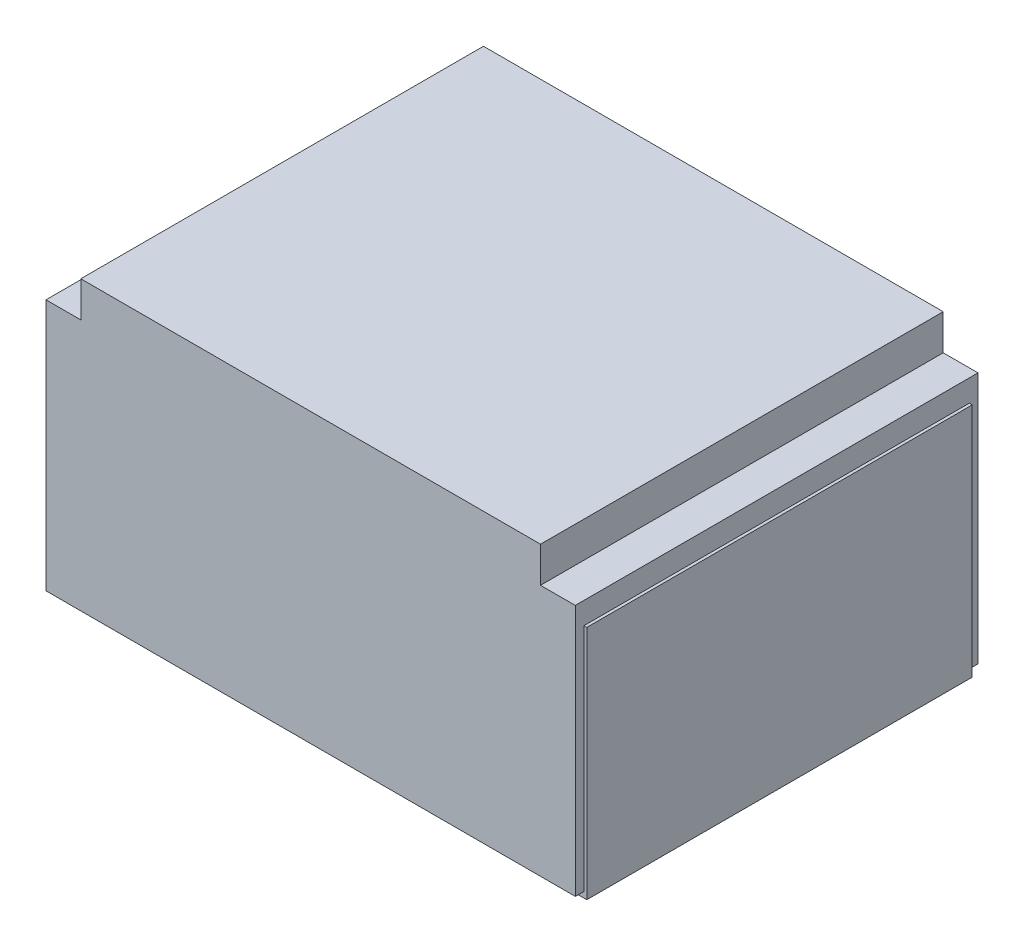
from build123d import *

# Parameters (mm, degrees)
SZKIC1_W                    = 4.6
SZKIC1_H                    = 2.5
DODANIE_WYCI_GNI_CIE1_DEPTH = 3.5
SZKIC2_W                    = 0.302200239
SZKIC2_H                    = 0.309416308
WYTNIJ_WYCI_GNI_CIE1_DEPTH  = 4.5
SZKIC3_W                    = 4.65
SZKIC3_H                    = 3.35
DODANIE_WYCI_GNI_CIE2_DEPTH = 0.05
SZKIC4_R                    = 0.162382369
SZKIC4_R_2                  = 1.05
WYTNIJ_WYCI_GNI_CIE2_DEPTH  = 0.05
SZKIC5_R                    = 1
DODANIE_WYCI_GNI_CIE3_DEPTH = 0.4
ZAOKR_GLENIE1_R             = 0.05
SZKIC6_W                    = 0.025
SZKIC6_H                    = 3.35
DODANIE_WYCI_GNI_CIE4_DEPTH = 2


with BuildPart() as part:
    # Szkic1 → Dodanie-wyciągnięcie1 (new body)
    with BuildSketch(Plane.XY):
        Rectangle(SZKIC1_W, SZKIC1_H)
    extrude(amount=DODANIE_WYCI_GNI_CIE1_DEPTH)

    # Szkic2 → Wytnij-wyciągnięcie1 (cut, through all)
    with BuildSketch(Plane.XY.offset(3.5)):
        with Locations((-2.148899881, 1.095291846)):
            Rectangle(SZKIC2_W, SZKIC2_H)
        with Locations((2.148899881, 1.095291846)):
            Rectangle(SZKIC2_W, SZKIC2_H)
    extrude(amount=-WYTNIJ_WYCI_GNI_CIE1_DEPTH, mode=Mode.SUBTRACT)


with BuildPart() as body_2:
    # Szkic3 → Dodanie-wyciągnięcie2 (new body)
    with BuildSketch(Plane.XZ.offset(1.25)):
        with Locations((0, 1.75)):
            Rectangle(SZKIC3_W, SZKIC3_H)
    extrude(amount=DODANIE_WYCI_GNI_CIE2_DEPTH)

    # Szkic4 → Wytnij-wyciągnięcie2 (cut)
    with BuildSketch(Plane.XZ.offset(1.3)):
        with Locations((-1.92312306, 3.089394939)):
            Circle(SZKIC4_R)
        with Locations((1.92312306, 3.089394939)):
            Circle(SZKIC4_R)
        with Locations((0, 1.59590093)):
            Circle(SZKIC4_R_2)
        Polygon((-1.74824974, 0.075), (-1.74824974, 0.441313237), (-1.648322128, 0.441313237), (-1.473448808, 0.191494209), (1.473448808, 0.191494209), (1.648322128, 0.441313237), (1.74824974, 0.441313237), (1.74824974, 0.075), align=None)
    extrude(amount=-WYTNIJ_WYCI_GNI_CIE2_DEPTH, mode=Mode.SUBTRACT)

    # Szkic6 → Dodanie-wyciągnięcie4 (add)
    with BuildSketch(Plane(origin=(0, -1.25, 0), x_dir=(1, 0, 0), z_dir=(0, 1, 0))):
        with Locations((-2.3125, -1.75)):
            Rectangle(SZKIC6_W, SZKIC6_H)
        with Locations((2.3125, -1.75)):
            Rectangle(SZKIC6_W, SZKIC6_H)
    extrude(amount=DODANIE_WYCI_GNI_CIE4_DEPTH)


with BuildPart() as body_3:
    # Szkic5 → Dodanie-wyciągnięcie3 (new body)
    with BuildSketch(Plane.XZ.offset(1.25)):
        with Locations((0, 1.59590093)):
            Circle(SZKIC5_R)
    extrude(amount=DODANIE_WYCI_GNI_CIE3_DEPTH)

    # Zaokrąglenie1
    zaokr_glenie1_edges = [body_3.edges().sort_by_distance(p)[0] for p in [
        (-1, -1.65, 1.59590093),
    ]]
    fillet(zaokr_glenie1_edges, radius=ZAOKR_GLENIE1_R)


solid = Compound([part.part, body_2.part, body_3.part])
